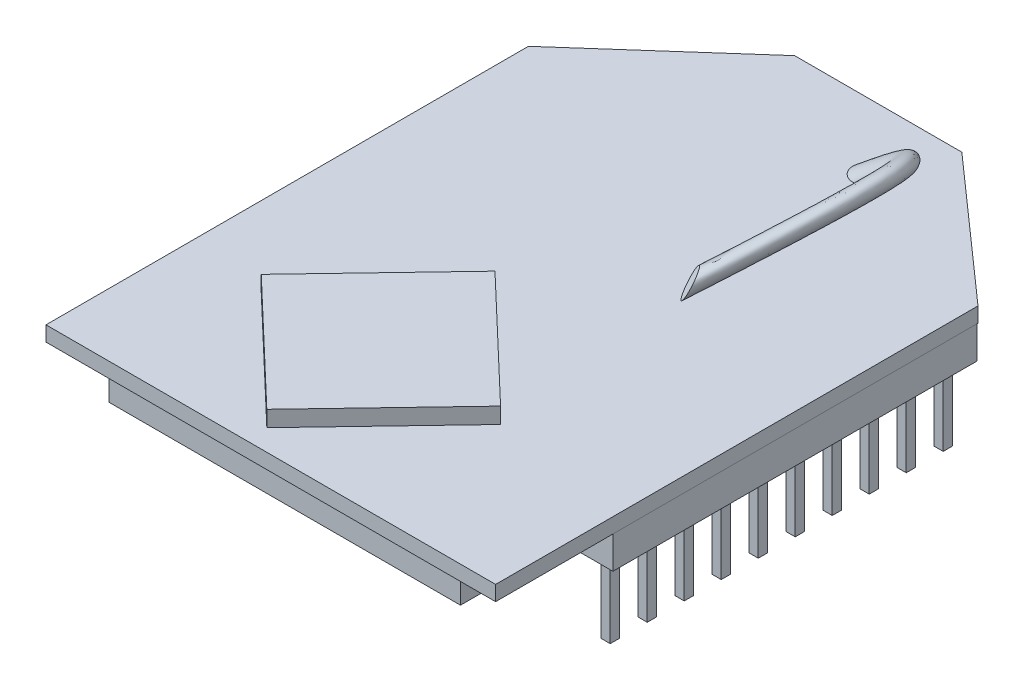
from build123d import *

# Parameters (mm, degrees)
BOSS_EXTRUDE1_DEPTH = 0.8128
SKETCH2_W           = 19.05
SKETCH2_H           = 24.2062
BOSS_EXTRUDE2_DEPTH = 1.8796
BOSS_EXTRUDE3_DEPTH = 0.8636
SKETCH4_W           = 1.9812
SKETCH4_H           = 19.75
BOSS_EXTRUDE4_DEPTH = 1.778
SKETCH5_W           = 0.508
SKETCH5_H           = 0.508
BOSS_EXTRUDE5_DEPTH = 4.064
SKETCH6_R           = 0.762


with BuildPart() as part:
    # Sketch1 → Boss-Extrude1 (new body)
    with BuildSketch(Plane(origin=(0, 0, 0), x_dir=(1, 0, 0), z_dir=(0, 1, 0))):
        Polygon((0, 0), (24.384, 0), (24.384, 26.162), (16.7259, 32.9438), (7.6581, 32.9438), (0, 26.162), align=None)
    extrude(amount=BOSS_EXTRUDE1_DEPTH)

    # Sketch2 → Boss-Extrude2 (add)
    with BuildSketch(Plane(origin=(0, 0, 0), x_dir=(-1, 0, 0), z_dir=(0, -1, 0))):
        with Locations((-12.192, 12.8651)):
            Rectangle(SKETCH2_W, SKETCH2_H)
    extrude(amount=BOSS_EXTRUDE2_DEPTH)

    # Sketch3 → Boss-Extrude3 (add)
    with BuildSketch(Plane(origin=(0, 0.8128, 0), x_dir=(1, 0, 0), z_dir=(0, 1, 0))):
        Polygon((4.3307, 7.342503403), (10.517503403, 13.832203403), (17.007203403, 7.6454), (10.8204, 1.1557), align=None)
    extrude(amount=BOSS_EXTRUDE3_DEPTH)

    # Sketch4 → Boss-Extrude4 (add)
    with BuildSketch(Plane(origin=(0, 0, 0), x_dir=(-1, 0, 0), z_dir=(0, -1, 0))):
        with Locations((-1.016, 16.2616)):
            Rectangle(SKETCH4_W, SKETCH4_H)
        with Locations((-23.368, 16.2616)):
            Rectangle(SKETCH4_W, SKETCH4_H)
    extrude(amount=BOSS_EXTRUDE4_DEPTH)

    # Sketch5 → Boss-Extrude5 (add)
    with BuildSketch(Plane(origin=(0, -1.778, 0), x_dir=(-1, 0, 0), z_dir=(0, -1, 0))):
        with Locations((-23.368, 25.2913)):
            Rectangle(SKETCH5_W, SKETCH5_H)
        with Locations((-23.368, 23.2847)):
            Rectangle(SKETCH5_W, SKETCH5_H)
        with Locations((-23.368, 21.2781)):
            Rectangle(SKETCH5_W, SKETCH5_H)
        with Locations((-23.368, 19.2715)):
            Rectangle(SKETCH5_W, SKETCH5_H)
        with Locations((-23.368, 17.2649)):
            Rectangle(SKETCH5_W, SKETCH5_H)
        with Locations((-23.368, 15.2583)):
            Rectangle(SKETCH5_W, SKETCH5_H)
        with Locations((-23.368, 13.2517)):
            Rectangle(SKETCH5_W, SKETCH5_H)
        with Locations((-23.368, 11.2451)):
            Rectangle(SKETCH5_W, SKETCH5_H)
        with Locations((-23.368, 9.2385)):
            Rectangle(SKETCH5_W, SKETCH5_H)
        with Locations((-23.368, 7.2319)):
            Rectangle(SKETCH5_W, SKETCH5_H)
        with Locations((-1.016, 7.2319)):
            Rectangle(SKETCH5_W, SKETCH5_H)
        with Locations((-1.016, 9.2385)):
            Rectangle(SKETCH5_W, SKETCH5_H)
        with Locations((-1.016, 11.2451)):
            Rectangle(SKETCH5_W, SKETCH5_H)
        with Locations((-1.016, 13.2517)):
            Rectangle(SKETCH5_W, SKETCH5_H)
        with Locations((-1.016, 15.2583)):
            Rectangle(SKETCH5_W, SKETCH5_H)
        with Locations((-1.016, 17.2649)):
            Rectangle(SKETCH5_W, SKETCH5_H)
        with Locations((-1.016, 19.2715)):
            Rectangle(SKETCH5_W, SKETCH5_H)
        with Locations((-1.016, 21.2781)):
            Rectangle(SKETCH5_W, SKETCH5_H)
        with Locations((-1.016, 23.2847)):
            Rectangle(SKETCH5_W, SKETCH5_H)
        with Locations((-1.016, 25.2913)):
            Rectangle(SKETCH5_W, SKETCH5_H)
    extrude(amount=BOSS_EXTRUDE5_DEPTH)

    # Sweep2: sweep along a curve in space
    with BuildLine() as sweep2_path:
        add(Edge.make_bspline(
            [(15.1892, 0.8128, -29.337), (20.622976284, 5.000023383, -30.448552109), (16.989821563, 2.292008104, -17.951240105)],
            knots=[0, 0, 0, 1, 1, 1], degree=2))
    # Sketch6 → Sweep2 (sweep)
    with BuildSketch(Plane(origin=(0, 0.8128, 0), x_dir=(1, 0, 0), z_dir=(0, 1, 0))):
        with Locations((15.1892, 29.337)):
            Circle(SKETCH6_R)
    sweep(path=sweep2_path.line)


solid = part.part
